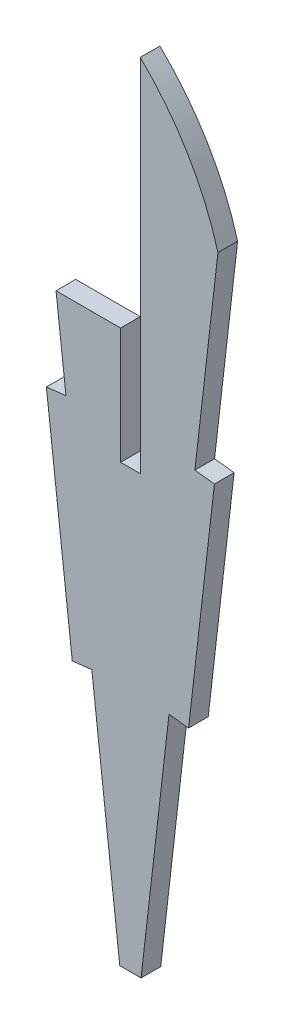
from build123d import *

# Parameters (mm, degrees)
BOSS_EXTRUDE1_DEPTH = 1.524
SKETCH2_W           = 10.339952981
SKETCH2_H           = 21.008044078
CUT_EXTRUDE1_DEPTH  = 1.524


with BuildPart() as part:
    # Sketch1 → Boss-Extrude1 (new body)
    with BuildSketch(Plane.XY):
        with BuildLine():
            Line((0, -185.062075144), (-1.524, -185.062075144))
            Line((-1.524, -185.062075144), (-1.524, -157.15233073))
            ThreePointArc((-1.524, -157.15233073), (-5.202982181, -161.792523258), (-7.537553978, -167.234588225))
            Line((-7.537553978, -167.234588225), (-5.752935589, -182.708365208))
            Line((-5.752935589, -182.708365208), (-7.266899912, -182.882973423))
            Line((-7.266899912, -182.882973423), (-5.263633807, -200.252565221))
            Line((-5.263633807, -200.252565221), (-3.749669484, -200.077957006))
            Line((-3.749669484, -200.077957006), (-1.585117021, -218.846004156))
            Line((-1.585117021, -218.846004156), (0.061117021, -218.846004156))
            Line((0.061117021, -218.846004156), (2.225669484, -200.077957006))
            Line((2.225669484, -200.077957006), (3.739633807, -200.252565221))
            Line((3.739633807, -200.252565221), (5.742899912, -182.882973423))
            Line((5.742899912, -182.882973423), (4.228935589, -182.708365208))
            Line((4.228935589, -182.708365208), (6.013553978, -167.234588225))
            ThreePointArc((6.013553978, -167.234588225), (3.678982181, -161.792523258), (0, -157.15233073))
            Line((0, -157.15233073), (0, -185.062075144))
        make_face()
    extrude(amount=BOSS_EXTRUDE1_DEPTH)

    # Sketch2 → Cut-Extrude1 (cut)
    with BuildSketch(Plane.XY.offset(1.524)):
        with Locations((-6.693976491, -165.555147297)):
            Rectangle(SKETCH2_W, SKETCH2_H)
    extrude(amount=-CUT_EXTRUDE1_DEPTH, mode=Mode.SUBTRACT)


solid = part.part
